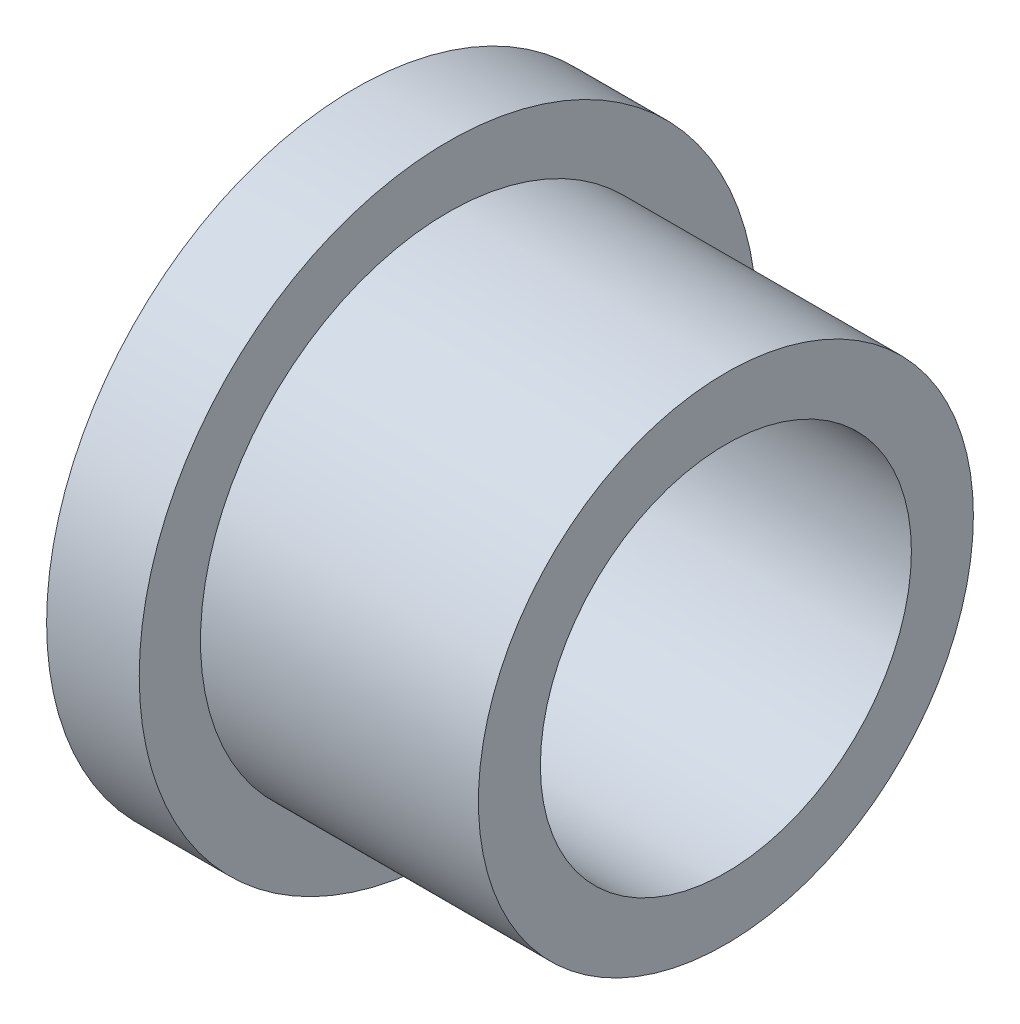
from build123d import *

# Parameters (mm, degrees)
SKETCH1_R           = 15.875
SKETCH1_R_2         = 9.5377
BOSS_EXTRUDE1_DEPTH = 4.7625
SKETCH1_3_R         = 12.7254
SKETCH1_3_R_2       = 9.5377
BOSS_EXTRUDE2_DEPTH = 19.05


with BuildPart() as part:
    # Sketch1 → Boss-Extrude1 (new body)
    with BuildSketch(Plane(origin=(0, 0, 0), x_dir=(0, 0, -1), z_dir=(1, 0, 0))):
        Circle(SKETCH1_R)
        Circle(SKETCH1_R_2, mode=Mode.SUBTRACT)
    extrude(amount=BOSS_EXTRUDE1_DEPTH)

    # Sketch1_3 → Boss-Extrude2 (add)
    with BuildSketch(Plane(origin=(0, 0, 0), x_dir=(0, 0, -1), z_dir=(1, 0, 0))):
        Circle(SKETCH1_3_R)
        Circle(SKETCH1_3_R_2, mode=Mode.SUBTRACT)
    extrude(amount=BOSS_EXTRUDE2_DEPTH)


solid = part.part
